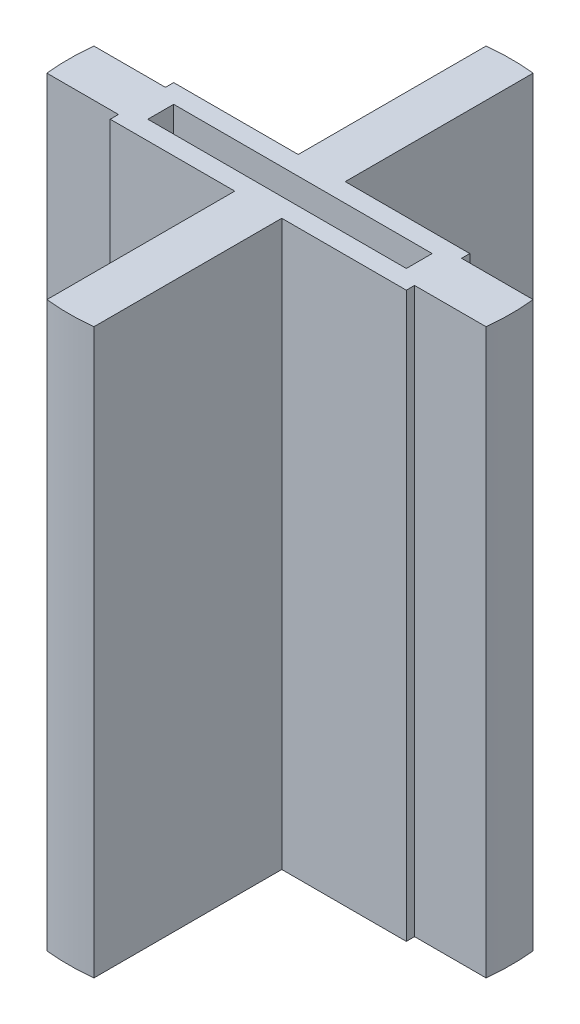
from build123d import *

# Parameters (mm, degrees)
SKETCH1_W           = 19.346272943
SKETCH1_H           = 12.7
SKETCH1_W_2         = 33.655
SKETCH1_H_2         = 2.2225
SKETCH1_W_3         = 12.7
SKETCH1_H_3         = 2.8575
SKETCH1_H_4         = 50.778772943
BOSS_EXTRUDE1_DEPTH = 76.2
SKETCH2_W           = 80.01
SKETCH2_H           = 17.145
BOSS_EXTRUDE2_DEPTH = 6.35


with BuildPart() as part:
    # Sketch1 → Boss-Extrude1 (new body, symmetric)
    with BuildSketch(Plane(origin=(0, 0, 0), x_dir=(1, 0, 0), z_dir=(0, 1, 0))):
        with Locations((-49.678136472, 0)):
            Rectangle(SKETCH1_W, SKETCH1_H)
        with BuildLine():
            ThreePointArc((-59.351272943, 6.35), (-59.69, 0), (-59.351272943, -6.35))
            Line((-59.351272943, -6.35), (-59.351272943, 6.35))
        make_face()
        with Locations((-23.1775, -7.46125)):
            Rectangle(SKETCH1_W_2, SKETCH1_H_2)
        Polygon((-6.35, -3.4925), (-34.925, -3.4925), (-34.925, 3.4925), (-6.35, 3.4925), (-6.35, 6.35), (-40.005, 6.35), (-40.005, -6.35), (-6.35, -6.35), align=None)
        with Locations((-23.1775, 7.46125)):
            Rectangle(SKETCH1_W_2, SKETCH1_H_2)
        with Locations((0, 7.46125)):
            Rectangle(SKETCH1_W_3, SKETCH1_H_2)
        with Locations((0, 4.92125)):
            Rectangle(SKETCH1_W_3, SKETCH1_H_3)
        with Locations((23.1775, 7.46125)):
            Rectangle(SKETCH1_W_2, SKETCH1_H_2)
        Polygon((34.925, -3.4925), (6.35, -3.4925), (6.35, -6.35), (40.005, -6.35), (40.005, 6.35), (6.35, 6.35), (6.35, 3.4925), (34.925, 3.4925), align=None)
        with Locations((23.1775, -7.46125)):
            Rectangle(SKETCH1_W_2, SKETCH1_H_2)
        with Locations((0, -7.46125)):
            Rectangle(SKETCH1_W_3, SKETCH1_H_2)
        with Locations((0, -4.92125)):
            Rectangle(SKETCH1_W_3, SKETCH1_H_3)
        with Locations((0, -33.961886472)):
            Rectangle(SKETCH1_W_3, SKETCH1_H_4)
        with BuildLine():
            Line((6.35, -59.351272943), (-6.35, -59.351272943))
            ThreePointArc((-6.35, -59.351272943), (0, -59.69), (6.35, -59.351272943))
        make_face()
        with Locations((49.678136472, 0)):
            Rectangle(SKETCH1_W, SKETCH1_H)
        with BuildLine():
            Line((59.351272943, 6.35), (59.351272943, -6.35))
            ThreePointArc((59.351272943, -6.35), (59.605258082, -3.179513957), (59.69, 0))
            ThreePointArc((59.69, 0), (59.605258082, 3.179513957), (59.351272943, 6.35))
        make_face()
        with Locations((0, 33.961886472)):
            Rectangle(SKETCH1_W_3, SKETCH1_H_4)
        with BuildLine():
            ThreePointArc((6.35, 59.351272943), (0, 59.69), (-6.35, 59.351272943))
            Line((-6.35, 59.351272943), (6.35, 59.351272943))
        make_face()
    extrude(amount=BOSS_EXTRUDE1_DEPTH, both=True)

    # Sketch2 → Boss-Extrude2 (add)
    with BuildSketch(Plane.XZ.offset(76.2)):
        Rectangle(SKETCH2_W, SKETCH2_H)
    extrude(amount=-BOSS_EXTRUDE2_DEPTH)


solid = part.part
